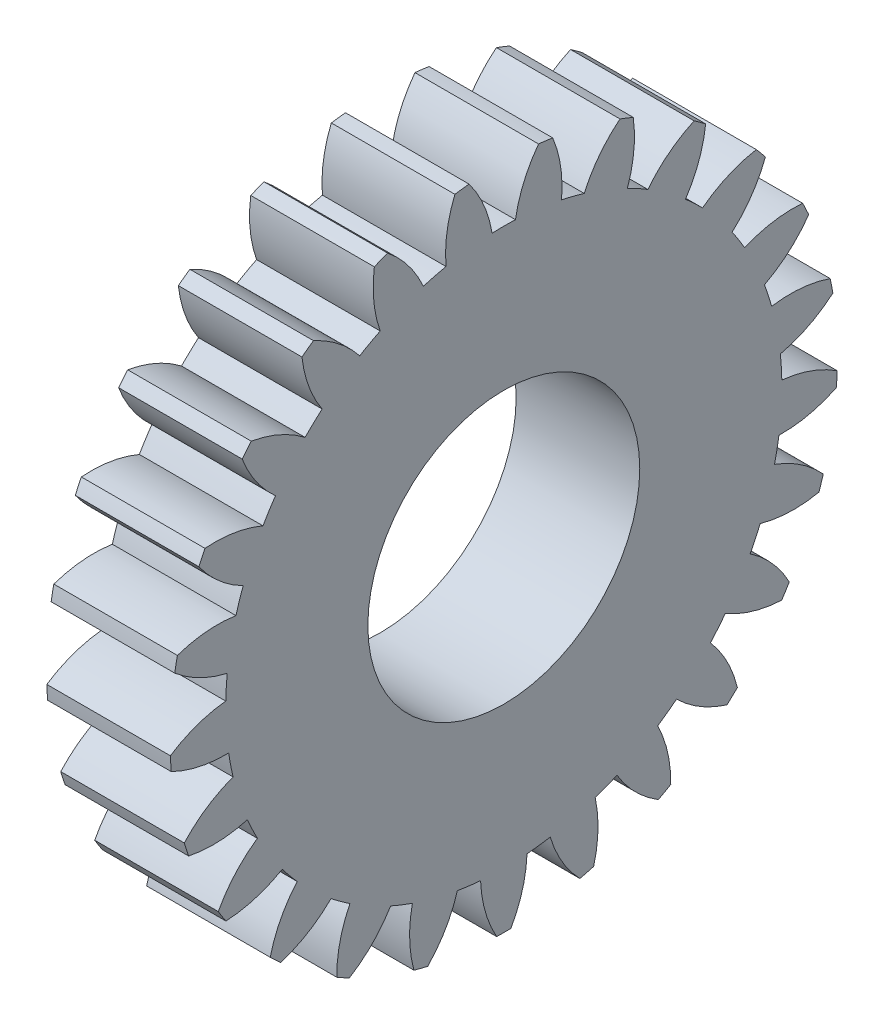
from build123d import *

# Parameters (mm, degrees)
BASPROSKE_W     = 10
BASPROSKE_H     = 27
TOOTHCUT_DEPTH  = 40.471508712
TEETHCUTS_COUNT = 25
TEETHCUTS_ANGLE = 345.6
BORSKE_R        = 11
BORE_DEPTH      = 50.0000508


with BuildPart() as part:
    # BasProSke → Base-Revolve (revolve)
    with BuildSketch(Plane(origin=(0, 0, 0), x_dir=(1, 0, 0), z_dir=(0, 1, 0)), mode=Mode.PRIVATE) as base_revolve_sk:
        with Locations((5, 13.5)):
            Rectangle(BASPROSKE_W, BASPROSKE_H)
    revolve(base_revolve_sk.sketch.rotate(Axis((-10, 0, 0), (1, 0, 0)), 180), axis=Axis((-10, 0, 0), (1, 0, 0)))

    # TooCutSke → ToothCut (cut, through all)
    with BuildSketch(Plane(origin=(0, 0, 0), x_dir=(0, 0, -1), z_dir=(1, 0, 0))):
        with BuildLine():
            ThreePointArc((0.946154762, 22.479096783), (0, 22.499), (-0.946154762, 22.479096783))
            ThreePointArc((-0.946154762, 22.479096783), (-1.62094792, 24.792268013), (-2.829470045, 26.876873784))
            ThreePointArc((-2.829470045, 26.876873784), (0, 27.0254), (2.829470045, 26.876873784))
            ThreePointArc((2.829470045, 26.876873784), (1.62094792, 24.792268013), (0.946154762, 22.479096783))
        make_face()
    toothcut = extrude(amount=TOOTHCUT_DEPTH, mode=Mode.SUBTRACT)

    # TeethCuts: ToothCut ×25 about axis
    teethcuts_axis = Axis((-10, 0, 0), (1, 0, 0))
    for i in range(1, TEETHCUTS_COUNT):
        add(toothcut.rotate(teethcuts_axis, i * TEETHCUTS_ANGLE / (TEETHCUTS_COUNT - 1)), mode=Mode.SUBTRACT)

    # BorSke → Bore (cut, symmetric)
    with BuildSketch(Plane(origin=(0, 0, 0), x_dir=(0, 0, -1), z_dir=(1, 0, 0))):
        with Locations(Location((0, 0, 0), (0, 0, 180))):
            Circle(BORSKE_R)
    extrude(amount=BORE_DEPTH, both=True, mode=Mode.SUBTRACT)


solid = part.part
